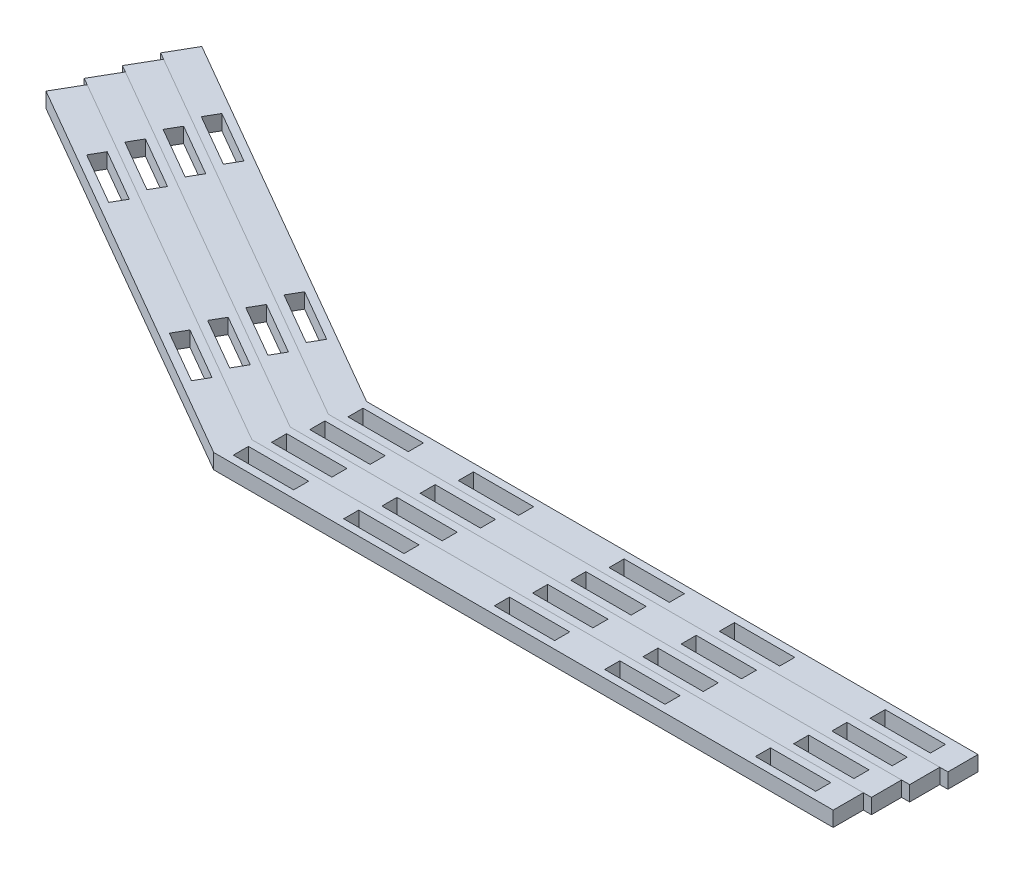
from build123d import *

# Parameters (mm, degrees)
BOSS_EXTRUDE2_DEPTH = 6.35
LPATTERN1_COUNT     = 4
LPATTERN1_PITCH     = 13.148007486


with BuildPart() as part:
    # Sketch4 → Boss-Extrude2 (new body)
    with BuildSketch(Plane(origin=(0, 0, 0), x_dir=(1, 0, 0), z_dir=(0, 1, 0))):
        Polygon((-428.205616447, 90.176116322), (-421.855616447, 101.17463895), (-257.614523887, 6.349999946), (-1e-09, 6.35), (1e-09, -6.35), (-261.017478725, -6.35), align=None)
        Polygon((-396.37217922, 75.463246979), (-374.375133964, 62.763246979), (-371.200133964, 68.262508293), (-393.19717922, 80.962508293), align=None, mode=Mode.SUBTRACT)
        Polygon((-313.88325951, 27.838246978), (-291.886214254, 15.138246977), (-288.711214254, 20.637508291), (-310.70825951, 33.337508292), align=None, mode=Mode.SUBTRACT)
        Polygon((-255.913065771, 3.174999946), (-255.913065769, -3.175000054), (-230.513065769, -3.175000048), (-230.513065771, 3.174999952), align=None, mode=Mode.SUBTRACT)
        Polygon((-209.427839463, 3.174999956), (-209.427839461, -3.175000044), (-184.027839461, -3.175000038), (-184.027839463, 3.174999962), align=None, mode=Mode.SUBTRACT)
        Polygon((-120.527839461, -3.175000025), (-120.527839463, 3.174999975), (-145.927839463, 3.174999969), (-145.927839461, -3.175000031), align=None, mode=Mode.SUBTRACT)
        Polygon((-99.442613155, 3.174999979), (-99.442613153, -3.175000021), (-74.042613153, -3.175000015), (-74.042613155, 3.174999985), align=None, mode=Mode.SUBTRACT)
        Polygon((-10.542613153, -3.175000002), (-10.542613155, 3.174999998), (-35.942613155, 3.174999993), (-35.942613153, -3.175000007), align=None, mode=Mode.SUBTRACT)
    extrude(amount=BOSS_EXTRUDE2_DEPTH)


with BuildPart() as lpattern1_1:
    # LPattern1: pattern copy
    add(part.part.moved(Location(Vector(0.258819053, 0, -0.965925824) * (1 * LPATTERN1_PITCH))))


with BuildPart() as lpattern1_2:
    # LPattern1: pattern copy
    add(part.part.moved(Location(Vector(0.258819053, 0, -0.965925824) * (2 * LPATTERN1_PITCH))))


with BuildPart() as lpattern1_3:
    # LPattern1: pattern copy
    add(part.part.moved(Location(Vector(0.258819053, 0, -0.965925824) * (3 * LPATTERN1_PITCH))))


solid = Compound([part.part, lpattern1_1.part, lpattern1_2.part, lpattern1_3.part])
